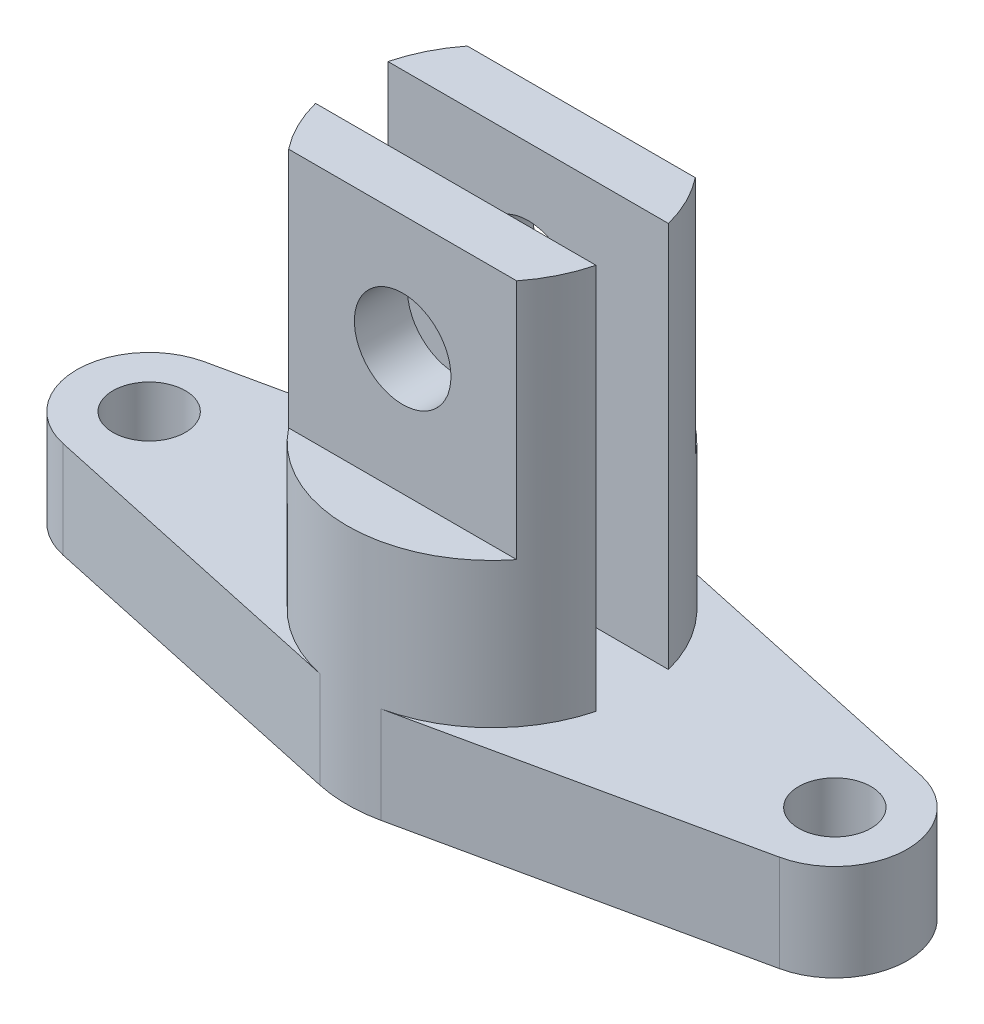
from build123d import *

# Parameters (mm, degrees)
CROQUIS1_R              = 7.5
SALIENTE_EXTRUIR1_DEPTH = 20
SALIENTE_EXTRUIR2_DEPTH = 80
CORTAR_EXTRUIR1_DEPTH   = 50
CROQUIS4_R              = 10
CORTAR_EXTRUIR2_DEPTH   = 37


with BuildPart() as part:
    # Croquis1 → Saliente-Extruir1 (new body)
    with BuildSketch(Plane(origin=(0, 0, 0), x_dir=(1, 0, 0), z_dir=(0, 1, 0))):
        with BuildLine():
            Line((6.338028169, 1.369942014), (74.169014085, 16.031365878))
            ThreePointArc((74.169014085, 16.031365878), (86, 30.692789743), (74.169014085, 45.354213607))
            Line((74.169014085, 45.354213607), (6.338028169, 60.015637472))
            ThreePointArc((6.338028169, 60.015637472), (0, 60.692789743), (-6.338028169, 60.015637472))
            Line((-6.338028169, 60.015637472), (-74.169014085, 45.354213607))
            ThreePointArc((-74.169014085, 45.354213607), (-86, 30.692789743), (-74.169014085, 16.031365878))
            Line((-74.169014085, 16.031365878), (-6.338028169, 1.369942014))
            ThreePointArc((-6.338028169, 1.369942014), (0, 0.692789743), (6.338028169, 1.369942014))
        make_face()
        with Locations((-71, 30.692789743)):
            Circle(CROQUIS1_R, mode=Mode.SUBTRACT)
        with Locations((71, 30.692789743)):
            Circle(CROQUIS1_R, mode=Mode.SUBTRACT)
    extrude(amount=SALIENTE_EXTRUIR1_DEPTH)

    # Croquis2 → Saliente-Extruir2 (add)
    with BuildSketch(Plane(origin=(0, 20, 0), x_dir=(1, 0, 0), z_dir=(0, 1, 0))):
        with BuildLine():
            Line((-29.047375097, 23.192789743), (29.047375097, 23.192789743))
            ThreePointArc((29.047375097, 23.192789743), (0, 0.692789743), (-29.047375097, 23.192789743))
        make_face()
        with BuildLine():
            Line((-29.047375097, 38.192789743), (29.047375097, 38.192789743))
            ThreePointArc((29.047375097, 38.192789743), (0, 60.692789743), (-29.047375097, 38.192789743))
        make_face()
    extrude(amount=SALIENTE_EXTRUIR2_DEPTH)

    # Croquis3 → Cortar-Extruir1 (cut)
    with BuildSketch(Plane(origin=(0, 100, 0), x_dir=(1, 0, 0), z_dir=(0, 1, 0))):
        with BuildLine():
            Line((-23.616731357, 49.192789743), (23.616731357, 49.192789743))
            ThreePointArc((23.616731357, 49.192789743), (0, 60.692789743), (-23.616731357, 49.192789743))
        make_face()
        with BuildLine():
            Line((-23.616731357, 12.192789743), (23.616731357, 12.192789743))
            ThreePointArc((23.616731357, 12.192789743), (0, 0.692789743), (-23.616731357, 12.192789743))
        make_face()
    extrude(amount=-CORTAR_EXTRUIR1_DEPTH, mode=Mode.SUBTRACT)

    # Croquis4 → Cortar-Extruir2 (cut)
    with BuildSketch(Plane.XY.offset(-12.192789743)):
        with Locations((0, 76)):
            Circle(CROQUIS4_R)
    extrude(amount=-CORTAR_EXTRUIR2_DEPTH, mode=Mode.SUBTRACT)


solid = part.part
